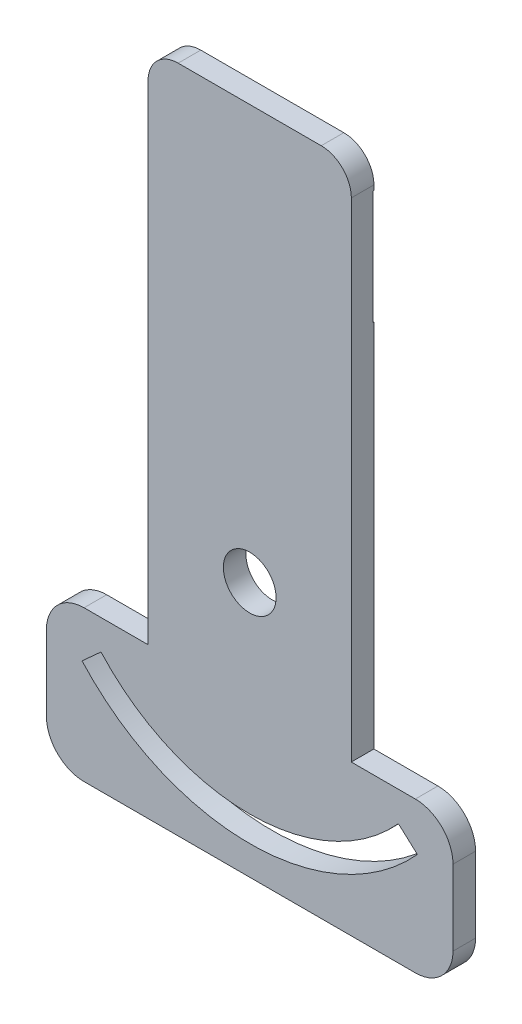
from build123d import *

# Parameters (mm, degrees)
CORTE_EXTERIOR_R        = 3.500001168
SALIENTE_EXTRUIR1_DEPTH = 3
CORTAR_EXTRUIR1_DEPTH   = 1
CORTAR_EXTRUIR2_DEPTH   = 0.1


with BuildPart() as part:
    # Corte exterior → Saliente-Extruir1 (new body)
    with BuildSketch(Plane.XY):
        with BuildLine():
            Line((19.521996462, -6.085833738), (11.021996462, -6.085833738))
            ThreePointArc((11.021996462, -6.085833738), (7.486462556, -7.550299832), (6.021996462, -11.085833738))
            Line((6.021996462, -11.085833738), (6.021996462, -21.085833738))
            ThreePointArc((6.021996462, -21.085833738), (7.486462556, -24.621367644), (11.021996462, -26.085833738))
            Line((11.021996462, -26.085833738), (55.021996462, -26.085833738))
            ThreePointArc((55.021996462, -26.085833738), (58.557530368, -24.621367644), (60.021996462, -21.085833738))
            Line((60.021996462, -21.085833738), (60.021996462, -11.085833738))
            ThreePointArc((60.021996462, -11.085833738), (58.557530368, -7.550299832), (55.021996462, -6.085833738))
            Line((55.021996462, -6.085833738), (46.514841363, -6.085833738))
            Line((46.514841363, -6.085833738), (46.521996462, 58.812041738))
            ThreePointArc((46.521996462, 58.812041738), (45.350423587, 61.640468863), (42.521996462, 62.812041738))
            Line((42.521996462, 62.812041738), (23.521996462, 62.812041738))
            ThreePointArc((23.521996462, 62.812041738), (20.693569337, 61.640468863), (19.521996462, 58.812041738))
            Line((19.521996462, 58.812041738), (19.521996462, -6.085833738))
        make_face()
        with Locations((33.021996462, 7.812041474)):
            Circle(CORTE_EXTERIOR_R, mode=Mode.SUBTRACT)
        with BuildLine():
            Line((55.29494797, -12.330366391), (52.77320204, -10.049840692))
            ThreePointArc((52.77320204, -10.049840692), (33.021996462, -18.817961696), (13.270789317, -10.049842109))
            Line((13.270789317, -10.049842109), (10.749043386, -12.330367808))
            ThreePointArc((10.749043386, -12.330367808), (33.021996462, -22.217961696), (55.29494797, -12.330366391))
        make_face(mode=Mode.SUBTRACT)
    extrude(amount=SALIENTE_EXTRUIR1_DEPTH)

    # Grabado Superficie → Cortar-Extruir1 (cut)
    with BuildSketch(Plane.XY):
        with BuildLine():
            Line((35.89134848, 9.816243852), (35.017032688, 22.202862127))
            ThreePointArc((35.017032688, 22.202862127), (33.021996462, 24.062041474), (31.026960236, 22.202862127))
            Line((31.026960236, 22.202862127), (30.152644444, 9.816243852))
            ThreePointArc((30.152644444, 9.816243852), (33.021996462, 11.312042642), (35.89134848, 9.816243852))
        make_face()
    extrude(amount=CORTAR_EXTRUIR1_DEPTH, mode=Mode.SUBTRACT)

    # grabado linea medio → Cortar-Extruir2 (cut)
    with BuildSketch(Plane.XY):
        Polygon((42.460122518, 43.017187336), (46.540121977, 43.015086813), (46.547921712, 58.165084805), (38.407922791, 58.169275554), (38.41031162, 62.809274939), (35.890311954, 62.810572321), (35.887922498, 58.169356436), (19.547821697, 57.977768849), (19.535965697, 34.948988401), (35.875963531, 34.940576014), (35.873574702, 30.300576629), (38.393574368, 30.299279247), (38.395963198, 34.939278632), (42.455962659, 34.937188407), align=None)
    extrude(amount=CORTAR_EXTRUIR2_DEPTH, mode=Mode.SUBTRACT)


solid = part.part
